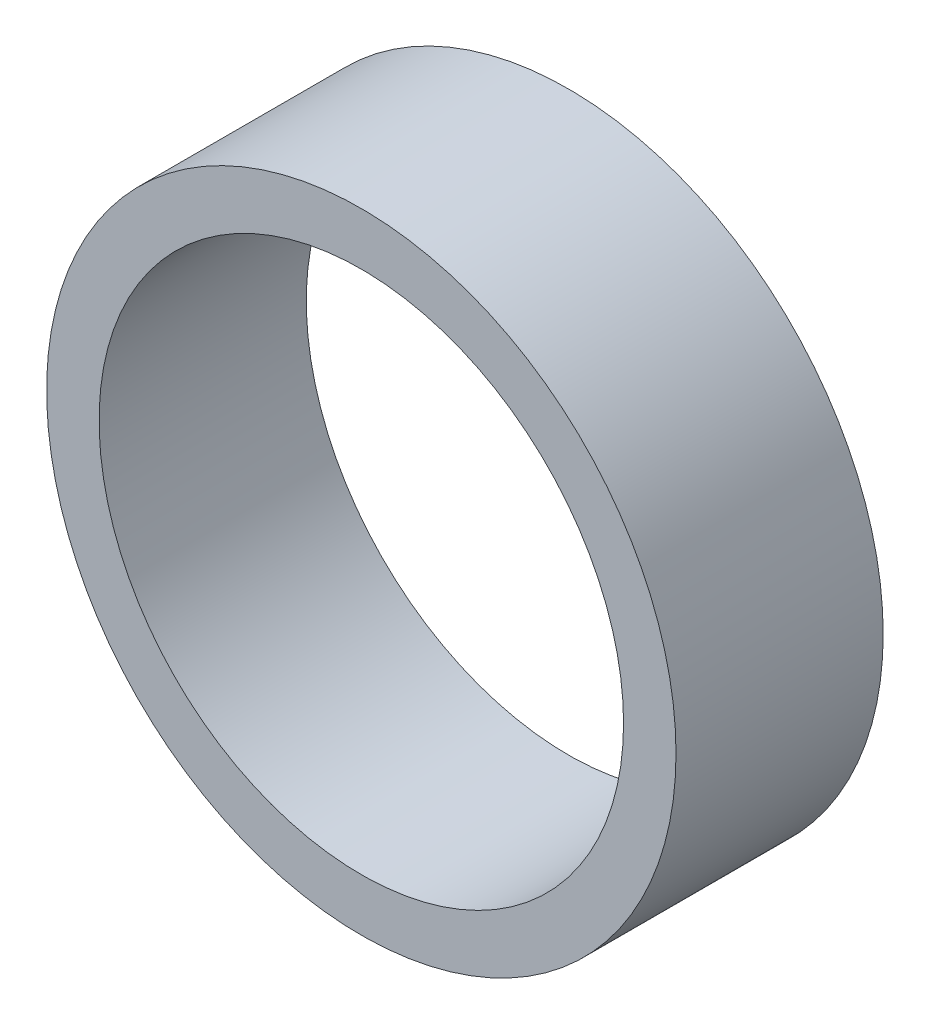
from build123d import *

# Parameters (mm, degrees)
SKETCH1_R           = 24
SKETCH1_R_2         = 20
BOSS_EXTRUDE1_DEPTH = 15.8


with BuildPart() as part:
    # Sketch1 → Boss-Extrude1 (new body)
    with BuildSketch(Plane.XY):
        Circle(SKETCH1_R)
        Circle(SKETCH1_R_2, mode=Mode.SUBTRACT)
    extrude(amount=BOSS_EXTRUDE1_DEPTH)


solid = part.part
